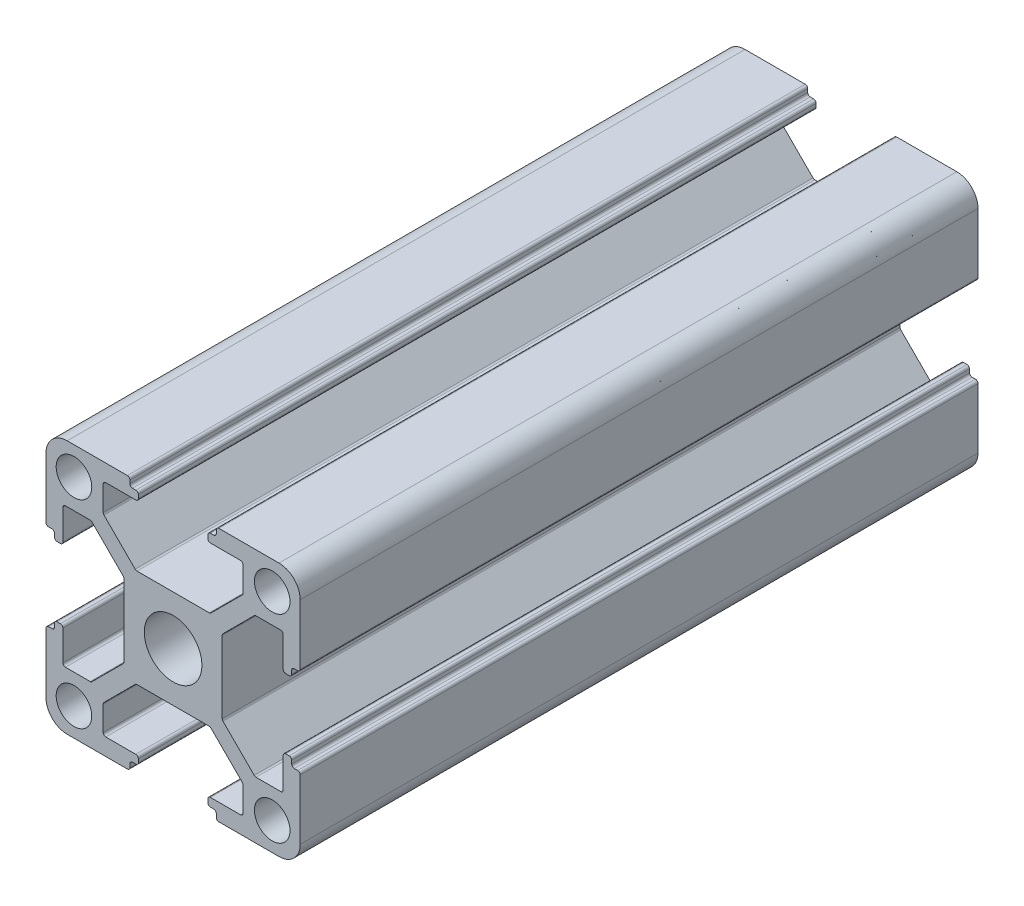
from build123d import *

# Parameters (mm, degrees)
CROQUIS1_R              = 2.1
CROQUIS1_R_2            = 3.4
SALIENTE_EXTRUIR1_DEPTH = 400
CROQUIS2_W              = 38.422022472
CROQUIS2_H              = 31.615605493
CORTAR_EXTRUIR1_DEPTH   = 320


with BuildPart() as part:
    # Croquis1 → Saliente-Extruir1 (new body)
    with BuildSketch(Plane(origin=(0, 0, -50), x_dir=(-1, 0, 0), z_dir=(0, 0, -1))):
        with BuildLine():
            Line((14.7, -5.1), (14.3, -5.1))
            ThreePointArc((14.3, -5.1), (14.087867966, -5.012132034), (14, -4.8))
            Line((14, -4.8), (14, -4.4))
            ThreePointArc((14, -4.4), (13.912132034, -4.187867966), (13.7, -4.1))
            Line((13.7, -4.1), (13.3, -4.1))
            ThreePointArc((13.3, -4.1), (13.087867966, -4.187867966), (13, -4.4))
            Line((13, -4.4), (13, -7.95))
            ThreePointArc((13, -7.95), (12.912132034, -8.162132034), (12.7, -8.25))
            Line((12.7, -8.25), (9.789264108, -8.25))
            ThreePointArc((9.789264108, -8.25), (9.674477865, -8.22717164), (9.577160832, -8.162160788))
            Line((9.577160832, -8.162160788), (5.887896723, -4.473896751))
            ThreePointArc((5.887896723, -4.473896751), (5.822843922, -4.376559778), (5.8, -4.261735963))
            Line((5.8, -4.261735963), (5.8, 4.260735931))
            ThreePointArc((5.8, 4.260735931), (5.82283614, 4.375540961), (5.887867966, 4.472867966))
            Line((5.887867966, 4.472867966), (9.577132034, 8.162132034))
            ThreePointArc((9.577132034, 8.162132034), (9.674459039, 8.22716386), (9.789264069, 8.25))
            Line((9.789264069, 8.25), (12.7, 8.25))
            ThreePointArc((12.7, 8.25), (12.912132034, 8.162132034), (13, 7.95))
            Line((13, 7.95), (13, 4.4))
            ThreePointArc((13, 4.4), (13.087867966, 4.187867966), (13.3, 4.1))
            Line((13.3, 4.1), (13.7, 4.1))
            ThreePointArc((13.7, 4.1), (13.912132034, 4.187867966), (14, 4.4))
            Line((14, 4.4), (14, 4.8))
            ThreePointArc((14, 4.8), (14.087867966, 5.012132034), (14.3, 5.1))
            Line((14.3, 5.1), (14.7, 5.1))
            ThreePointArc((14.7, 5.1), (14.912132034, 5.187867966), (15, 5.4))
            Line((15, 5.4), (15, 12.5))
            ThreePointArc((15, 12.5), (14.267766953, 14.267766953), (12.5, 15))
            Line((12.5, 15), (5.4, 15))
            ThreePointArc((5.4, 15), (5.187867966, 14.912132034), (5.1, 14.7))
            Line((5.1, 14.7), (5.1, 14.3))
            ThreePointArc((5.1, 14.3), (5.012132034, 14.087867966), (4.8, 14))
            Line((4.8, 14), (4.4, 14))
            ThreePointArc((4.4, 14), (4.187867966, 13.912132034), (4.1, 13.7))
            Line((4.1, 13.7), (4.1, 13.3))
            ThreePointArc((4.1, 13.3), (4.187867966, 13.087867966), (4.4, 13))
            Line((4.4, 13), (7.95, 13))
            ThreePointArc((7.95, 13), (8.162132034, 12.912132034), (8.25, 12.7))
            Line((8.25, 12.7), (8.25, 9.788264069))
            ThreePointArc((8.25, 9.788264069), (8.22716386, 9.673459039), (8.162132034, 9.576132034))
            Line((8.162132034, 9.576132034), (4.473867966, 5.887867966))
            ThreePointArc((4.473867966, 5.887867966), (4.376540961, 5.82283614), (4.261735931, 5.8))
            Line((4.261735931, 5.8), (-4.260735892, 5.8))
            ThreePointArc((-4.260735892, 5.8), (-4.375522135, 5.82282836), (-4.472839168, 5.887839212))
            Line((-4.472839168, 5.887839212), (-8.162103277, 9.576103249))
            ThreePointArc((-8.162103277, 9.576103249), (-8.227156078, 9.673440222), (-8.25, 9.788264037))
            Line((-8.25, 9.788264037), (-8.25, 12.7))
            ThreePointArc((-8.25, 12.7), (-8.162132034, 12.912132034), (-7.95, 13))
            Line((-7.95, 13), (-4.4, 13))
            ThreePointArc((-4.4, 13), (-4.187867966, 13.087867966), (-4.1, 13.3))
            Line((-4.1, 13.3), (-4.1, 13.7))
            ThreePointArc((-4.1, 13.7), (-4.187867966, 13.912132034), (-4.4, 14))
            Line((-4.4, 14), (-4.8, 14))
            ThreePointArc((-4.8, 14), (-5.012132034, 14.087867966), (-5.1, 14.3))
            Line((-5.1, 14.3), (-5.1, 14.7))
            ThreePointArc((-5.1, 14.7), (-5.187867966, 14.912132034), (-5.4, 15))
            Line((-5.4, 15), (-12.5, 15))
            ThreePointArc((-12.5, 15), (-14.267766953, 14.267766953), (-15, 12.5))
            Line((-15, 12.5), (-15, 5.4))
            ThreePointArc((-15, 5.4), (-14.912132034, 5.187867966), (-14.7, 5.1))
            Line((-14.7, 5.1), (-14.3, 5.1))
            ThreePointArc((-14.3, 5.1), (-14.087867966, 5.012132034), (-14, 4.8))
            Line((-14, 4.8), (-14, 4.4))
            ThreePointArc((-14, 4.4), (-13.912132034, 4.187867966), (-13.7, 4.1))
            Line((-13.7, 4.1), (-13.3, 4.1))
            ThreePointArc((-13.3, 4.1), (-13.087867966, 4.187867966), (-13, 4.4))
            Line((-13, 4.4), (-13, 7.95))
            ThreePointArc((-13, 7.95), (-12.912132034, 8.162132034), (-12.7, 8.25))
            Line((-12.7, 8.25), (-9.788264037, 8.25))
            ThreePointArc((-9.788264037, 8.25), (-9.673440222, 8.227156078), (-9.576103249, 8.162103277))
            Line((-9.576103249, 8.162103277), (-5.887839212, 4.472839168))
            ThreePointArc((-5.887839212, 4.472839168), (-5.82282836, 4.375522135), (-5.8, 4.260735892))
            Line((-5.8, 4.260735892), (-5.8, -4.261735931))
            ThreePointArc((-5.8, -4.261735931), (-5.82283614, -4.376540961), (-5.887867966, -4.473867966))
            Line((-5.887867966, -4.473867966), (-9.576132034, -8.162132034))
            ThreePointArc((-9.576132034, -8.162132034), (-9.673459039, -8.22716386), (-9.788264069, -8.25))
            Line((-9.788264069, -8.25), (-12.7, -8.25))
            ThreePointArc((-12.7, -8.25), (-12.912132034, -8.162132034), (-13, -7.95))
            Line((-13, -7.95), (-13, -4.4))
            ThreePointArc((-13, -4.4), (-13.087867966, -4.187867966), (-13.3, -4.1))
            Line((-13.3, -4.1), (-13.7, -4.1))
            ThreePointArc((-13.7, -4.1), (-13.912132034, -4.187867966), (-14, -4.4))
            Line((-14, -4.4), (-14, -4.8))
            ThreePointArc((-14, -4.8), (-14.087867966, -5.012132034), (-14.3, -5.1))
            Line((-14.3, -5.1), (-14.7, -5.1))
            ThreePointArc((-14.7, -5.1), (-14.912132034, -5.187867966), (-15, -5.4))
            Line((-15, -5.4), (-15, -12.5))
            ThreePointArc((-15, -12.5), (-14.267766953, -14.267766953), (-12.5, -15))
            Line((-12.5, -15), (-5.4, -15))
            ThreePointArc((-5.4, -15), (-5.187867966, -14.912132034), (-5.1, -14.7))
            Line((-5.1, -14.7), (-5.1, -14.3))
            ThreePointArc((-5.1, -14.3), (-5.012132034, -14.087867966), (-4.8, -14))
            Line((-4.8, -14), (-4.4, -14))
            ThreePointArc((-4.4, -14), (-4.187867966, -13.912132034), (-4.1, -13.7))
            Line((-4.1, -13.7), (-4.1, -13.3))
            ThreePointArc((-4.1, -13.3), (-4.187867966, -13.087867966), (-4.4, -13))
            Line((-4.4, -13), (-7.95, -13))
            ThreePointArc((-7.95, -13), (-8.162132034, -12.912132034), (-8.25, -12.7))
            Line((-8.25, -12.7), (-8.25, -9.789264069))
            ThreePointArc((-8.25, -9.789264069), (-8.22716386, -9.674459039), (-8.162132034, -9.577132034))
            Line((-8.162132034, -9.577132034), (-4.472867966, -5.887867966))
            ThreePointArc((-4.472867966, -5.887867966), (-4.375540961, -5.82283614), (-4.260735931, -5.8))
            Line((-4.260735931, -5.8), (4.261735963, -5.8))
            ThreePointArc((4.261735963, -5.8), (4.376559778, -5.822843922), (4.473896751, -5.887896723))
            Line((4.473896751, -5.887896723), (8.162160788, -9.577160832))
            ThreePointArc((8.162160788, -9.577160832), (8.22717164, -9.674477865), (8.25, -9.789264108))
            Line((8.25, -9.789264108), (8.25, -12.7))
            ThreePointArc((8.25, -12.7), (8.162132034, -12.912132034), (7.95, -13))
            Line((7.95, -13), (4.4, -13))
            ThreePointArc((4.4, -13), (4.187867966, -13.087867966), (4.1, -13.3))
            Line((4.1, -13.3), (4.1, -13.7))
            ThreePointArc((4.1, -13.7), (4.187867966, -13.912132034), (4.4, -14))
            Line((4.4, -14), (4.8, -14))
            ThreePointArc((4.8, -14), (5.012132034, -14.087867966), (5.1, -14.3))
            Line((5.1, -14.3), (5.1, -14.7))
            ThreePointArc((5.1, -14.7), (5.187867966, -14.912132034), (5.4, -15))
            Line((5.4, -15), (12.5, -15))
            ThreePointArc((12.5, -15), (14.267766953, -14.267766953), (15, -12.5))
            Line((15, -12.5), (15, -5.4))
            ThreePointArc((15, -5.4), (14.912132034, -5.187867966), (14.7, -5.1))
        make_face()
        with Locations((-11.7, 11.7)):
            Circle(CROQUIS1_R, mode=Mode.SUBTRACT)
        with Locations((-11.7, -11.7)):
            Circle(CROQUIS1_R, mode=Mode.SUBTRACT)
        Circle(CROQUIS1_R_2, mode=Mode.SUBTRACT)
        with Locations((11.7, 11.7)):
            Circle(CROQUIS1_R, mode=Mode.SUBTRACT)
        with Locations((11.7, -11.7)):
            Circle(CROQUIS1_R, mode=Mode.SUBTRACT)
    extrude(amount=-SALIENTE_EXTRUIR1_DEPTH)

    # Croquis2 → Cortar-Extruir1 (cut)
    with BuildSketch(Plane.XY.offset(350)):
        with Locations((1.308926342, 0.261785268)):
            Rectangle(CROQUIS2_W, CROQUIS2_H)
    extrude(amount=-CORTAR_EXTRUIR1_DEPTH, mode=Mode.SUBTRACT)


solid = part.part
